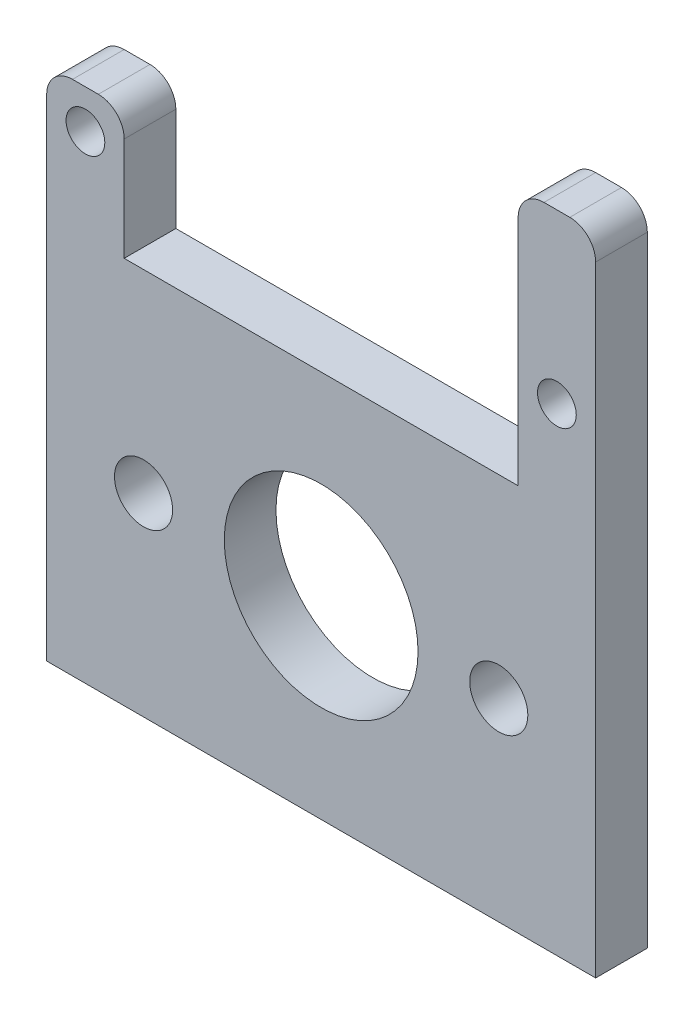
from build123d import *

# Parameters (mm, degrees)
SKETCH_1_R      = 1.5
SKETCH_1_R_2    = 2.25
SKETCH_1_R_3    = 7.5
EXTRUDE_1_DEPTH = 4
FILLET_1_R      = 2


with BuildPart() as part:
    # 草图1 → 凸台-拉伸1 (new body)
    with BuildSketch(Plane.XY):
        Polygon((-18.007870082, 20.608843809), (-18.007870082, -13.606505187), (-18.007870082, -19.391156191), (24.492129918, -19.391156191), (24.492129918, 30.608843809), (18.492129918, 30.608843809), (18.492129918, 10.608843809), (-12.007870082, 10.608843809), (-12.007870082, 20.608843809), align=None)
        with Locations((-15.007870082, 17.608843809)):
            Circle(SKETCH_1_R, mode=Mode.SUBTRACT)
        with Locations((21.492129918, 17.608843809)):
            Circle(SKETCH_1_R, mode=Mode.SUBTRACT)
        with Locations((-10.507870082, -4.391156191)):
            Circle(SKETCH_1_R_2, mode=Mode.SUBTRACT)
        with Locations((16.992129918, -4.391156191)):
            Circle(SKETCH_1_R_2, mode=Mode.SUBTRACT)
        with Locations((3.242129918, -4.391156191)):
            Circle(SKETCH_1_R_3, mode=Mode.SUBTRACT)
    extrude(amount=EXTRUDE_1_DEPTH)

    # 圆角1
    fillet_1_edges = [part.edges().sort_by_distance(p)[0] for p in [
        (-12.007870082, 20.608843809, 2),
        (18.492129918, 30.608843809, 2),
        (24.492129918, 30.608843809, 2),
        (-18.007870082, 20.608843809, 2),
    ]]
    fillet(fillet_1_edges, radius=FILLET_1_R)


solid = part.part
